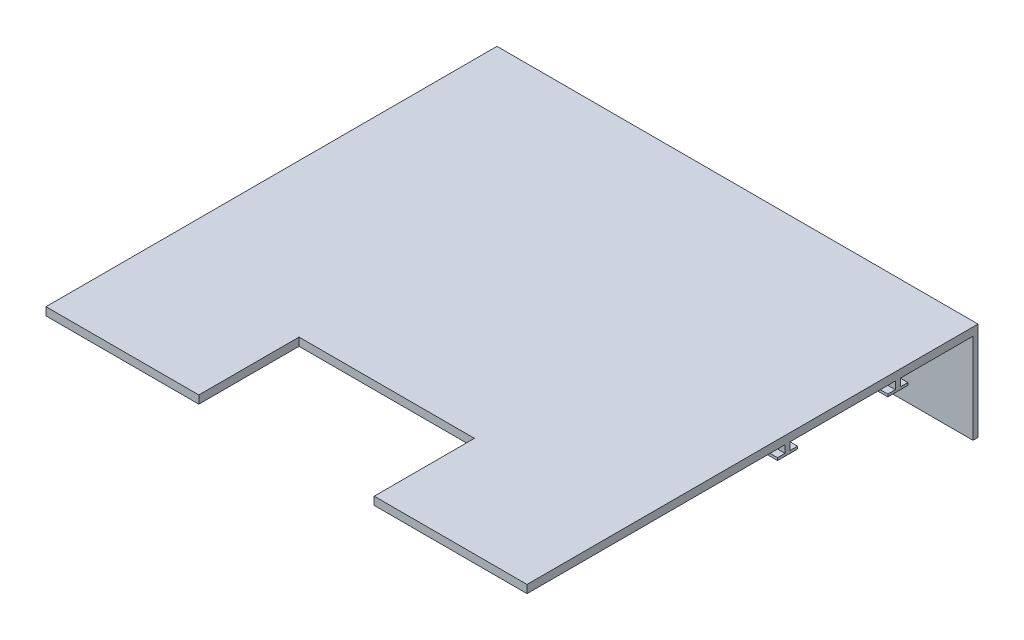
from build123d import *

# Parameters (mm, degrees)
SKETCH1_W           = 480
SKETCH1_H           = 450
BOSS_EXTRUDE1_DEPTH = 8
SKETCH2_W           = 175
SKETCH2_H           = 100
CUT_EXTRUDE1_DEPTH  = 10
SKETCH4_R           = 3.5
BOSS_EXTRUDE3_DEPTH = 15
BOSS_EXTRUDE4_DEPTH = 90
SKETCH9_W           = 480
SKETCH9_H           = 5
BOSS_EXTRUDE6_DEPTH = 7.5
SKETCH10_W          = 480
SKETCH10_H          = 20
BOSS_EXTRUDE7_DEPTH = 2.5


with BuildPart() as part:
    # Sketch1 → Boss-Extrude1 (new body)
    with BuildSketch(Plane(origin=(0, 0, 0), x_dir=(1, 0, 0), z_dir=(0, 1, 0))):
        with Locations((240, 225)):
            Rectangle(SKETCH1_W, SKETCH1_H)
    extrude(amount=BOSS_EXTRUDE1_DEPTH)

    # Sketch2 → Cut-Extrude1 (cut)
    with BuildSketch(Plane(origin=(0, 8, 0), x_dir=(1, 0, 0), z_dir=(0, 1, 0))):
        with Locations((240, 50)):
            Rectangle(SKETCH2_W, SKETCH2_H)
    extrude(amount=-CUT_EXTRUDE1_DEPTH, mode=Mode.SUBTRACT)

    # Sketch4 → Boss-Extrude3 (add)
    with BuildSketch(Plane.XZ):
        with Locations((30, -217)):
            Circle(SKETCH4_R)
        with Locations((450, -217)):
            Circle(SKETCH4_R)
    extrude(amount=BOSS_EXTRUDE3_DEPTH)

    # Sketch5 → Boss-Extrude4 (add)
    with BuildSketch(Plane.XZ):
        Polygon((5, -445), (0, -445), (0, -450), (480, -450), (480, -445), (475, -445), align=None)
    extrude(amount=BOSS_EXTRUDE4_DEPTH)

    # Sketch9 → Boss-Extrude6 (add)
    with BuildSketch(Plane.XZ):
        with Locations((240, -370)):
            Rectangle(SKETCH9_W, SKETCH9_H)
    boss_extrude6 = extrude(amount=BOSS_EXTRUDE6_DEPTH)

    # Sketch10 → Boss-Extrude7 (add)
    with BuildSketch(Plane.XZ.offset(7.5)):
        with Locations((240, -370)):
            Rectangle(SKETCH10_W, SKETCH10_H)
    boss_extrude7 = extrude(amount=BOSS_EXTRUDE7_DEPTH)

    # Mirror9: Boss-Extrude6, Boss-Extrude7 across plane
    add(boss_extrude6.mirror(Plane.XY.offset(-315)))
    add(boss_extrude7.mirror(Plane.XY.offset(-315)))


solid = part.part
